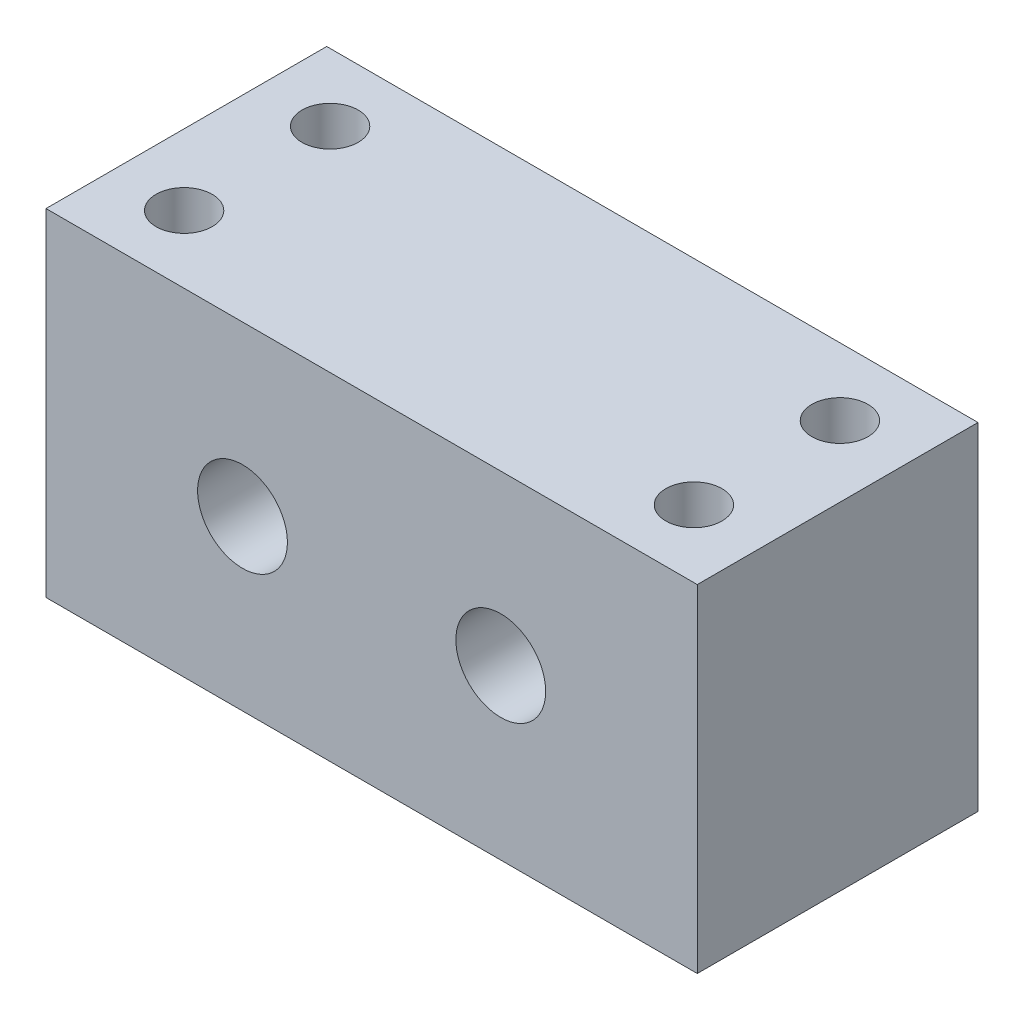
from build123d import *

# Parameters (mm, degrees)
ESQUISSE1_W                                   = 58
ESQUISSE1_H                                   = 30
BOSS_EXTRU_1_DEPTH                            = 25
TROU_POUR_TARAUDAGE_POUR_TROU_TARAUD_M6_D     = 5
TROU_POUR_TARAUDAGE_POUR_TROU_TARAUD_M6_DEPTH = 15
TROU_POUR_TARAUDAGE_POUR_TROU_TARAUD_M6_TIP   = 1.502151548
DIAM_TRE_DU_PER_AGE_8_0_8_1_D                 = 8


with BuildPart() as part:
    # Esquisse1 → Boss.-Extru.1 (new body)
    with BuildSketch(Plane.XY):
        with Locations((29, 15)):
            Rectangle(ESQUISSE1_W, ESQUISSE1_H)
    extrude(amount=BOSS_EXTRU_1_DEPTH)

    # Trou pour taraudage pour trou taraudé M61
    with Locations(Plane(origin=(6.3, 30, 6), x_dir=(0, 0, 1), z_dir=(0, 1, 0))):
        with Locations((0, 0), (13, 0), (13, 45.4), (0, 45.4)):
            Hole(TROU_POUR_TARAUDAGE_POUR_TROU_TARAUD_M6_D / 2, depth=TROU_POUR_TARAUDAGE_POUR_TROU_TARAUD_M6_DEPTH)
            with Locations((0, 0, -(TROU_POUR_TARAUDAGE_POUR_TROU_TARAUD_M6_DEPTH + TROU_POUR_TARAUDAGE_POUR_TROU_TARAUD_M6_TIP / 2))):  # 118° drill point
                Cone(0, TROU_POUR_TARAUDAGE_POUR_TROU_TARAUD_M6_D / 2, TROU_POUR_TARAUDAGE_POUR_TROU_TARAUD_M6_TIP, mode=Mode.SUBTRACT)

    # Diamètre du perçage Ø8.0 (8)1 (through all)
    with Locations(Plane(origin=(17.5, 15, 25), x_dir=(1, 0, 0), z_dir=(0, 0, 1))):
        with Locations((0, 0), (23, 0)):
            Hole(DIAM_TRE_DU_PER_AGE_8_0_8_1_D / 2)


solid = part.part
